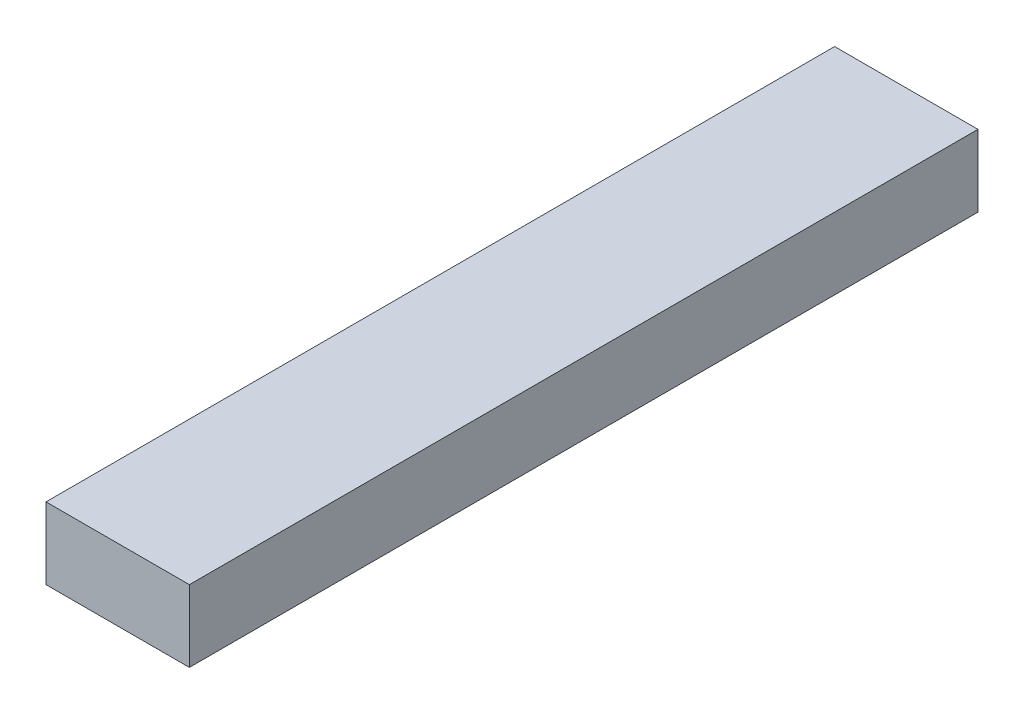
from build123d import *

# Parameters (mm, degrees)
SKETCH1_W           = 20
SKETCH1_H           = 110
BOSS_EXTRUDE1_DEPTH = 10


with BuildPart() as part:
    # Sketch1 → Boss-Extrude1 (new body)
    with BuildSketch(Plane(origin=(0, 0, 0), x_dir=(1, 0, 0), z_dir=(0, 1, 0))):
        Rectangle(SKETCH1_W, SKETCH1_H)
    extrude(amount=BOSS_EXTRUDE1_DEPTH)


solid = part.part
